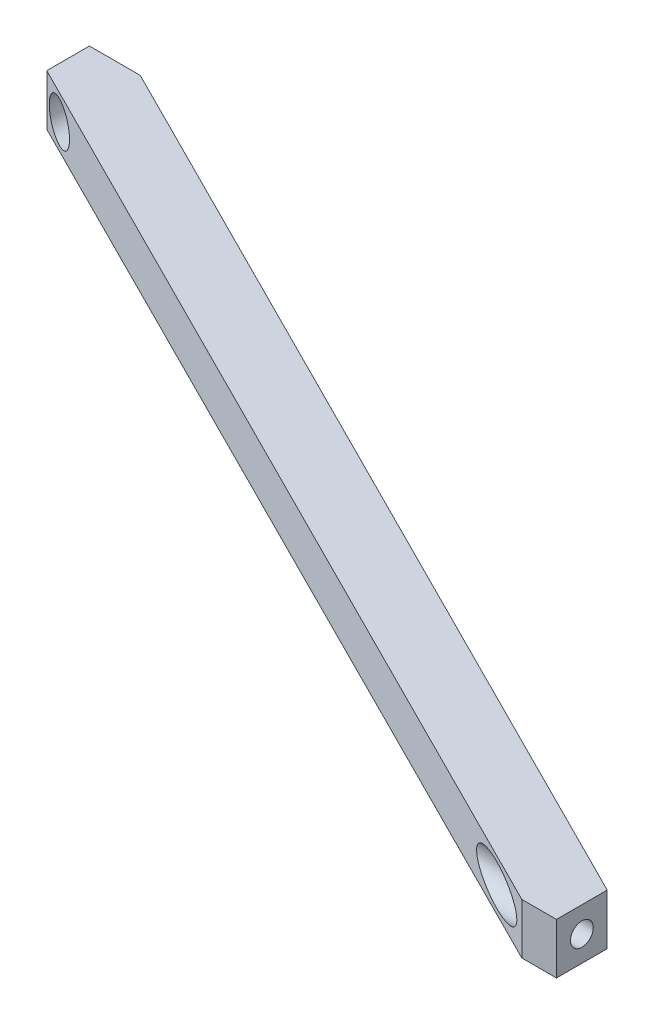
from build123d import *

# Parameters (mm, degrees)
BOSS_EXTRU_1_DEPTH      = 10
ESQUISSE4_R             = 2.1
ENL_V_MAT_EXTRU_1_DEPTH = 104
D_GAGEMENT_M41_D        = 4.5
ESQUISSE7_R             = 4
ENL_V_MAT_EXTRU_2_DEPTH = 12
ESQUISSE8_R             = 4
ENL_V_MAT_EXTRU_3_DEPTH = 28


with BuildPart() as part:
    # Esquisse1 → Boss.-Extru.1 (new body)
    with BuildSketch(Plane(origin=(0, 0, 0), x_dir=(1, 0, 0), z_dir=(0, 1, 0))):
        Polygon((-235, -22), (-235, -30.403916389), (-46.824994968, -125), (-40, -125), (-40, -115), (-225, -22), align=None)
    extrude(amount=BOSS_EXTRU_1_DEPTH)

    # Esquisse4 → Enlèv. mat.-Extru.1 (cut, through all)
    with BuildSketch(Plane(origin=(0, 0, 22), x_dir=(-1, 0, 0), z_dir=(0, 0, -1))):
        with Locations((230, 5)):
            Circle(ESQUISSE4_R)
    extrude(amount=-ENL_V_MAT_EXTRU_1_DEPTH, mode=Mode.SUBTRACT)

    # Dégagement M41 (through all)
    with Locations(Plane(origin=(-40, 0, 0), x_dir=(0, 0, -1), z_dir=(1, 0, 0))):
        with Locations((-120, 5)):
            Hole(D_GAGEMENT_M41_D / 2)

    # Esquisse7 → Enlèv. mat.-Extru.2 (cut)
    with BuildSketch(Plane(origin=(0, 0, 28), x_dir=(-1, 0, 0), z_dir=(0, 0, -1))):
        with Locations((230, 5)):
            Circle(ESQUISSE7_R)
    extrude(amount=-ENL_V_MAT_EXTRU_2_DEPTH, mode=Mode.SUBTRACT)

    # Esquisse8 → Enlèv. mat.-Extru.3 (cut)
    with BuildSketch(Plane(origin=(-46, 0, 0), x_dir=(0, 0, -1), z_dir=(1, 0, 0))):
        with Locations((-120, 5)):
            Circle(ESQUISSE8_R)
    extrude(amount=-ENL_V_MAT_EXTRU_3_DEPTH, mode=Mode.SUBTRACT)


solid = part.part
